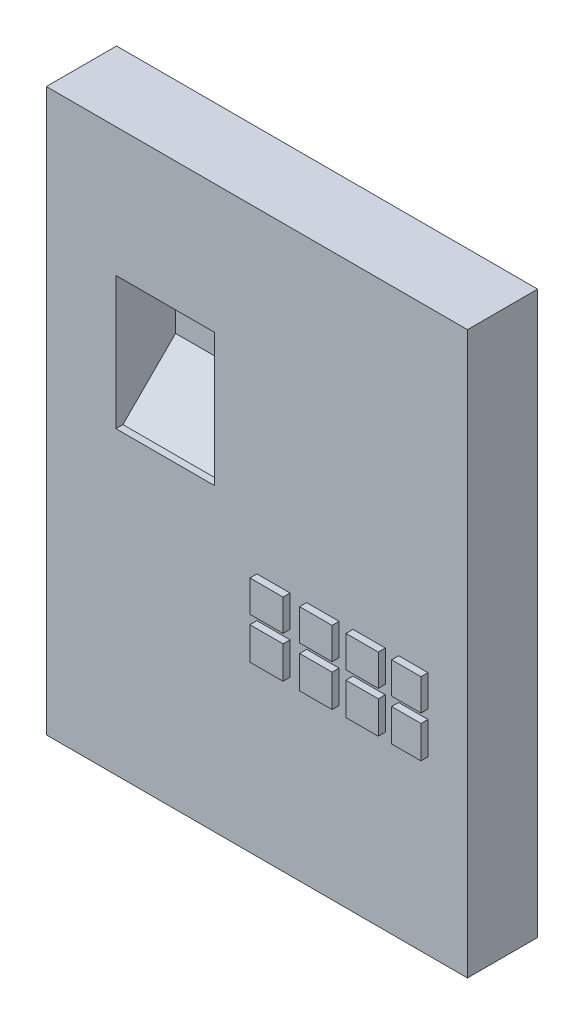
from build123d import *

# Parameters (mm, degrees)
CROQUIS1_W              = 120
CROQUIS1_H              = 160
SALIENTE_EXTRUIR1_DEPTH = 20
CROQUIS2_W              = 28.149997618
CROQUIS2_H              = 37.819844128
CORTAR_EXTRUIR1_DEPTH   = 17
CHAFL_N1_SIZE           = 15
CROQUIS3_W              = 9.454961032
CROQUIS3_H              = 9.240075554
CROQUIS3_W_2            = 9.240075554
CROQUIS3_W_3            = 9.215154211
CROQUIS3_W_4            = 8.355073151
CROQUIS3_H_2            = 8.969416765
SALIENTE_EXTRUIR2_DEPTH = 2


with BuildPart() as part:
    # Croquis1 → Saliente-Extruir1 (new body)
    with BuildSketch(Plane.XY):
        with Locations((60, -80)):
            Rectangle(CROQUIS1_W, CROQUIS1_H)
    extrude(amount=SALIENTE_EXTRUIR1_DEPTH)

    # Croquis2 → Cortar-Extruir1 (cut)
    with BuildSketch(Plane.XY.offset(20)):
        with Locations((33.891414423, -55.610498247)):
            Rectangle(CROQUIS2_W, CROQUIS2_H)
    extrude(amount=-CORTAR_EXTRUIR1_DEPTH, mode=Mode.SUBTRACT)

    # Chaflán1
    chafl_n1_edges = [part.edges().sort_by_distance(p)[0] for p in [
        (33.891414423, -74.520420311, 3),
    ]]
    chamfer(chafl_n1_edges, length=CHAFL_N1_SIZE)

    # Croquis3 → Saliente-Extruir2 (add)
    with BuildSketch(Plane.XY.offset(20)):
        with Locations((64.727480516, -106.430913794)):
            Rectangle(CROQUIS3_W, CROQUIS3_H)
        with Locations((78.802479325, -106.430913794)):
            Rectangle(CROQUIS3_W_2, CROQUIS3_H)
        with Locations((91.975896748, -106.430913794)):
            Rectangle(CROQUIS3_W_3, CROQUIS3_H)
        with Locations((104.569940836, -106.430913794)):
            Rectangle(CROQUIS3_W_4, CROQUIS3_H)
        with Locations((64.727480516, -94.755549816)):
            Rectangle(CROQUIS3_W, CROQUIS3_H_2)
        with Locations((78.802479325, -94.755549816)):
            Rectangle(CROQUIS3_W_2, CROQUIS3_H_2)
        with Locations((91.975896748, -94.755549816)):
            Rectangle(CROQUIS3_W_3, CROQUIS3_H_2)
        with Locations((104.569940836, -94.755549816)):
            Rectangle(CROQUIS3_W_4, CROQUIS3_H_2)
    extrude(amount=SALIENTE_EXTRUIR2_DEPTH)


solid = part.part
